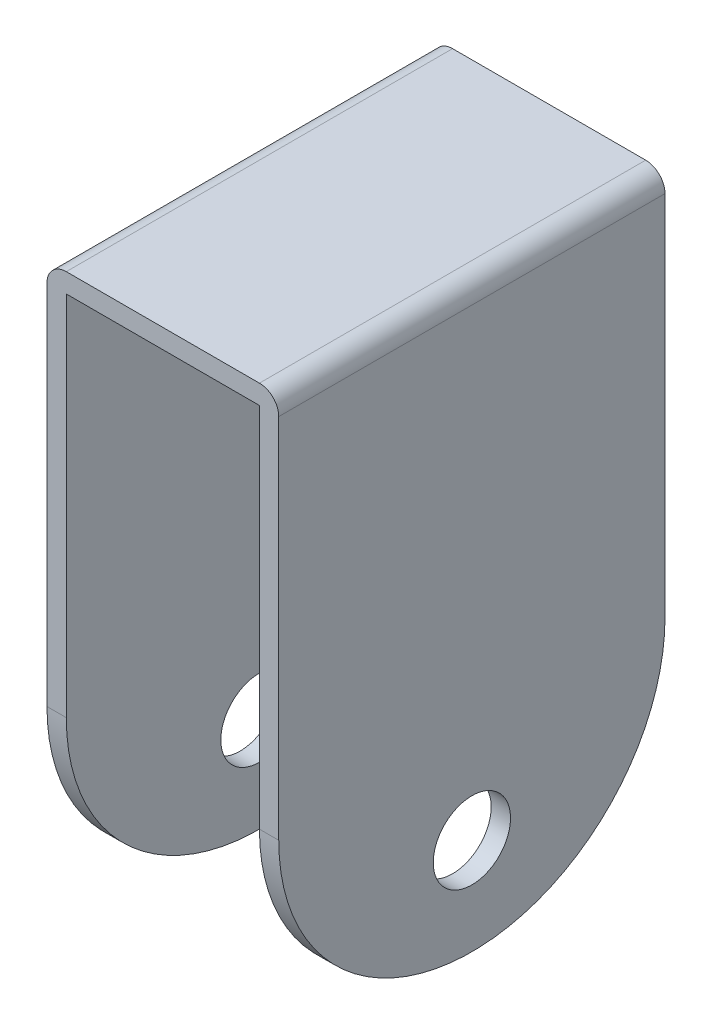
from build123d import *

# Parameters (mm, degrees)
SKETCH1_R           = 6
BOSS_EXTRUDE1_DEPTH = 3
SKETCH2_W           = 60
SKETCH2_H           = 3
BOSS_EXTRUDE2_DEPTH = 30
SKETCH3_R           = 6
BOSS_EXTRUDE4_DEPTH = 3
FILLET1_R           = 3


with BuildPart() as part:
    # Sketch1 → Boss-Extrude1 (new body)
    with BuildSketch(Plane(origin=(0, 0, 0), x_dir=(0, 0, -1), z_dir=(1, 0, 0))):
        with BuildLine():
            Line((0, 0), (60, 0))
            Line((60, 0), (60, -60))
            ThreePointArc((60, -60), (30, -90), (0, -60))
            Line((0, -60), (0, 0))
        make_face()
        with Locations((30, -75)):
            Circle(SKETCH1_R, mode=Mode.SUBTRACT)
    extrude(amount=-BOSS_EXTRUDE1_DEPTH)

    # Sketch2 → Boss-Extrude2 (add)
    with BuildSketch(Plane.ZY.offset(3)):
        with Locations((-30, -1.5)):
            Rectangle(SKETCH2_W, SKETCH2_H)
    extrude(amount=BOSS_EXTRUDE2_DEPTH)

    # Sketch3 → Boss-Extrude4 (add)
    with BuildSketch(Plane.ZY.offset(33)):
        with BuildLine():
            Line((-60, 0), (0, 0))
            Line((0, 0), (0, -60))
            ThreePointArc((0, -60), (-30, -90), (-60, -60))
            Line((-60, -60), (-60, 0))
        make_face()
        with Locations((-30, -75)):
            Circle(SKETCH3_R, mode=Mode.SUBTRACT)
    extrude(amount=BOSS_EXTRUDE4_DEPTH)

    # Fillet1
    fillet1_edges = [part.edges().sort_by_distance(p)[0] for p in [
        (-36, 0, -30),
        (0, 0, -30),
    ]]
    fillet(fillet1_edges, radius=FILLET1_R)


solid = part.part
